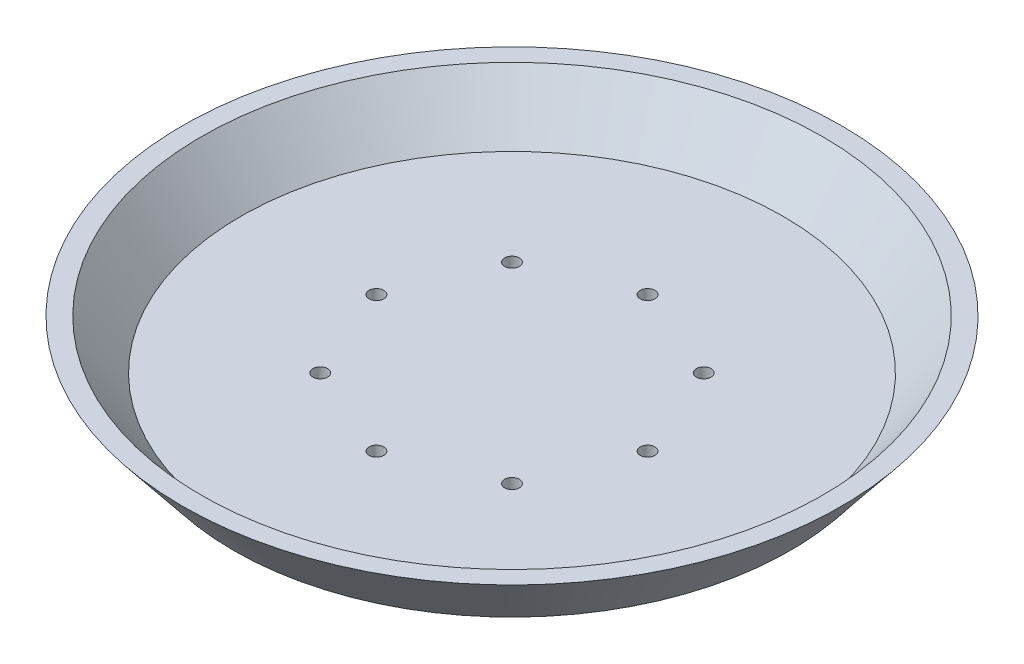
from build123d import *

# Parameters (mm, degrees)
SKETCH2_R          = 1.5
CUT_EXTRUDE1_DEPTH = 14


with BuildPart() as part:
    # Sketch1 → Revolve1 (revolve)
    with BuildSketch(Plane.XY):
        Polygon((55, 0), (63, 10), (66.841874542, 10), (56.441874542, -3), (0, -3), (0, 0), align=None)
    revolve(axis=Axis((0, -3, 0), (0, 1, 0)))

    # Sketch2 → Cut-Extrude1 (cut, through all)
    with BuildSketch(Plane(origin=(0, -3, 0), x_dir=(-1, 0, 0), z_dir=(0, -1, 0))):
        with Locations((0, -27.5)):
            Circle(SKETCH2_R)
        with Locations((-19.445436483, -19.445436483)):
            Circle(SKETCH2_R)
        with Locations((-27.5, 0)):
            Circle(SKETCH2_R)
        with Locations((-19.445436483, 19.445436483)):
            Circle(SKETCH2_R)
        with Locations((0, 27.5)):
            Circle(SKETCH2_R)
        with Locations((19.445436483, 19.445436483)):
            Circle(SKETCH2_R)
        with Locations((27.5, 0)):
            Circle(SKETCH2_R)
        with Locations((19.445436483, -19.445436483)):
            Circle(SKETCH2_R)
    extrude(amount=-CUT_EXTRUDE1_DEPTH, mode=Mode.SUBTRACT)


solid = part.part
